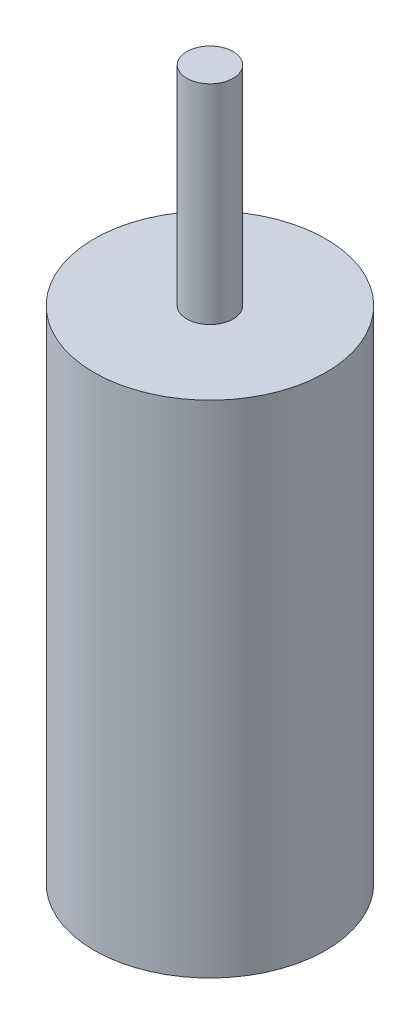
from build123d import *

# Parameters (mm, degrees)
SKETCH1_R           = 10
BOSS_EXTRUDE1_DEPTH = 43.2
SKETCH2_R           = 2
BOSS_EXTRUDE2_DEPTH = 18


with BuildPart() as part:
    # Sketch1 → Boss-Extrude1 (new body)
    with BuildSketch(Plane(origin=(0, 0, 0), x_dir=(1, 0, 0), z_dir=(0, 1, 0))):
        Circle(SKETCH1_R)
    extrude(amount=BOSS_EXTRUDE1_DEPTH)

    # Sketch2 → Boss-Extrude2 (add)
    with BuildSketch(Plane(origin=(0, 43.2, 0), x_dir=(1, 0, 0), z_dir=(0, 1, 0))):
        Circle(SKETCH2_R)
    extrude(amount=BOSS_EXTRUDE2_DEPTH)


solid = part.part
